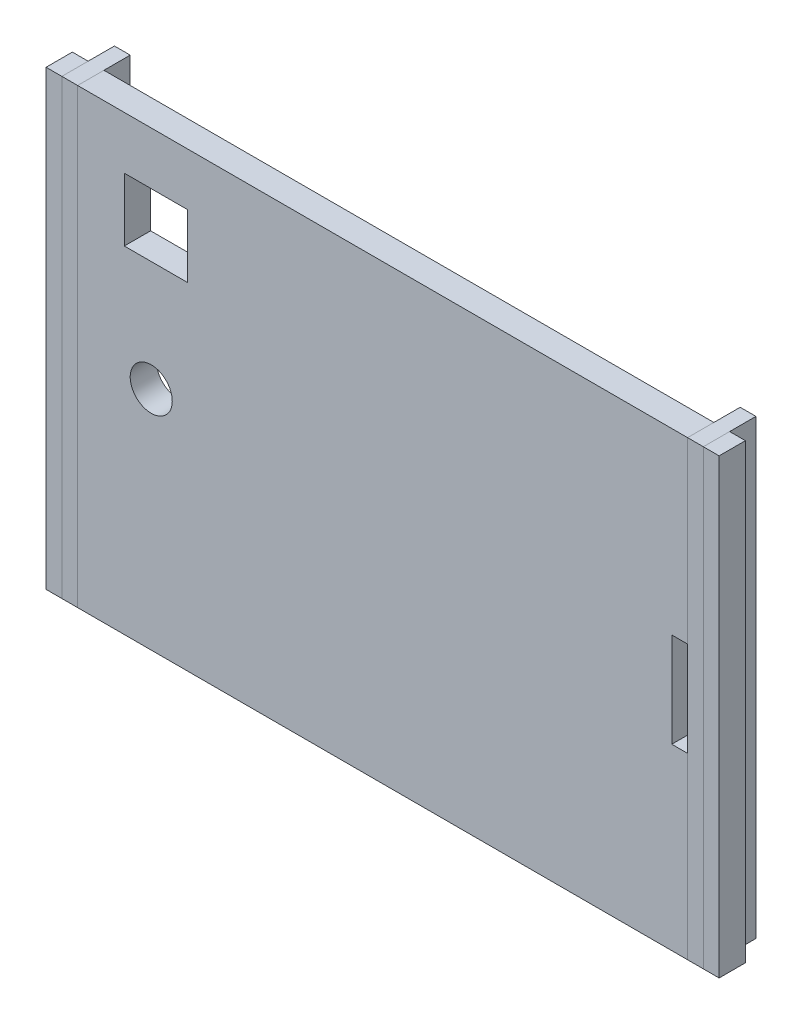
from build123d import *

# Parameters (mm, degrees)
SKETCH_1_W        = 3
SKETCH_1_H        = 86
EXTRUDE_1_DEPTH   = 5
SKETCH_1_R        = 4
SKETCH_1_W_2      = 12
SKETCH_1_H_2      = 12
EXTRUDE_1_2_DEPTH = 5
EXTRUDE_1_3_DEPTH = 5
SKETCH_1_5_W      = 3
SKETCH_1_5_H      = 86
EXTRUDE_3_DEPTH   = 10
EXTRUDE_3_2_DEPTH = 10


with BuildPart() as part:
    # Эскиз1 → Бобышка-Вытянуть1 (new body)
    with BuildSketch(Plane.XY):
        with Locations((-101.746338848, 5.223963701)):
            Rectangle(SKETCH_1_W, SKETCH_1_H)
    extrude(amount=-EXTRUDE_1_DEPTH)


with BuildPart() as body_2:
    # Эскиз1 → Extrude 1 2 (new body)
    with BuildSketch(Plane.XY):
        Polygon((18.753661152, 48.223963701), (-97.246338848, 48.223963701), (-97.246338848, -37.776036299), (18.753661152, -37.776036299), (18.753661152, -3.776036299), (15.753661152, -3.776036299), (15.753661152, 14.223963701), (18.753661152, 14.223963701), align=None)
        with Locations((-83.246338848, 5.223963701)):
            Circle(SKETCH_1_R, mode=Mode.SUBTRACT)
        with Locations((-82.363885902, 32.223963701)):
            Rectangle(SKETCH_1_W_2, SKETCH_1_H_2, mode=Mode.SUBTRACT)
    extrude(amount=-EXTRUDE_1_2_DEPTH)


with BuildPart() as body_3:
    # Эскиз1 → Extrude 1 3 (new body)
    with BuildSketch(Plane.XY):
        with Locations((23.253661152, 5.223963701)):
            Rectangle(SKETCH_1_W, SKETCH_1_H)
    extrude(amount=-EXTRUDE_1_3_DEPTH)


with BuildPart() as body_4:
    # Эскиз1<5> → Бобышка-Вытянуть3 (new body)
    with BuildSketch(Plane.XY):
        with Locations((-98.746338848, 5.223963701)):
            Rectangle(SKETCH_1_5_W, SKETCH_1_5_H)
    extrude(amount=-EXTRUDE_3_DEPTH)


with BuildPart() as body_5:
    # Эскиз1<5> → Extrude 3 2 (new body)
    with BuildSketch(Plane.XY):
        with Locations((20.253661152, 5.223963701)):
            Rectangle(SKETCH_1_5_W, SKETCH_1_5_H)
    extrude(amount=-EXTRUDE_3_2_DEPTH)


solid = Compound([part.part, body_2.part, body_3.part, body_4.part, body_5.part])
